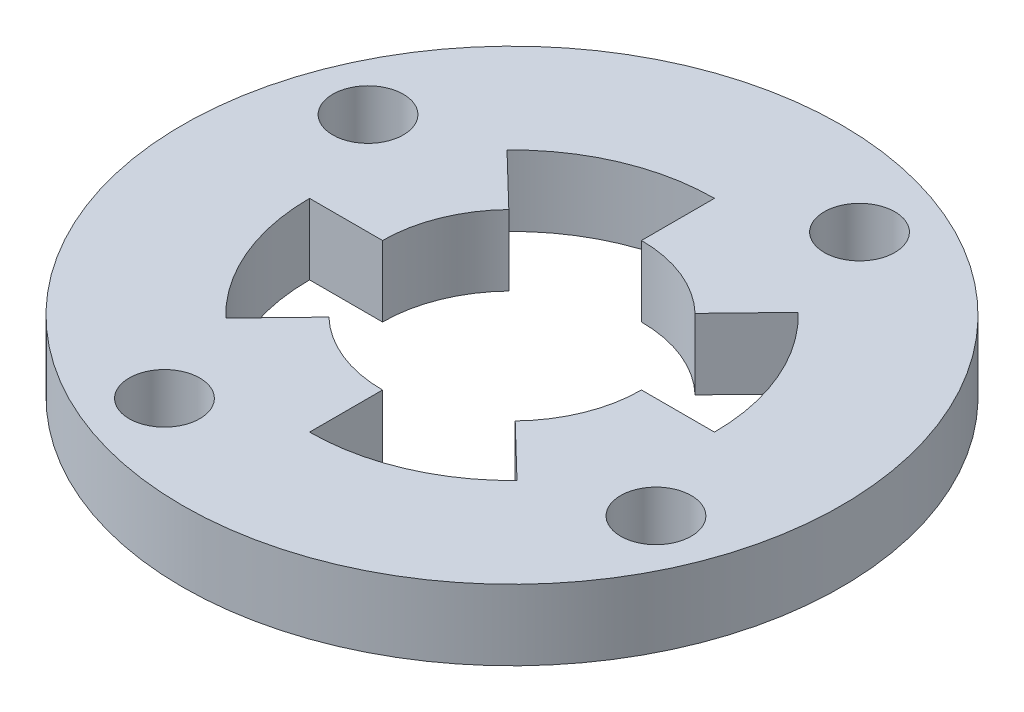
from build123d import *

# Parameters (mm, degrees)
SKETCH1_R           = 14
SKETCH1_R_2         = 1.5
BOSS_EXTRUDE1_DEPTH = 3


with BuildPart() as part:
    # Sketch1 → Boss-Extrude1 (new body)
    with BuildSketch(Plane(origin=(0, 0, 0), x_dir=(1, 0, 0), z_dir=(0, 1, 0))):
        Circle(SKETCH1_R)
        with Locations((-4.324322786, -10.439838717)):
            Circle(SKETCH1_R_2, mode=Mode.SUBTRACT)
        with Locations((10.439838717, -4.324322786)):
            Circle(SKETCH1_R_2, mode=Mode.SUBTRACT)
        with Locations((4.324322786, 10.439838717)):
            Circle(SKETCH1_R_2, mode=Mode.SUBTRACT)
        with Locations((-10.439838717, 4.324322786)):
            Circle(SKETCH1_R_2, mode=Mode.SUBTRACT)
        with BuildLine():
            ThreePointArc((-3.820621038, -3.956368902), (-2.060336264, -5.0995112), (0, -5.5))
            Line((0, -5.5), (0, -8.6))
            ThreePointArc((0, -8.6), (3.360287705, -7.91634174), (6.186322283, -5.974061986))
            Line((6.186322283, -5.974061986), (3.956368902, -3.820621038))
            ThreePointArc((3.956368902, -3.820621038), (5.0995112, -2.060336264), (5.5, 0))
            Line((5.5, 0), (8.6, 0))
            ThreePointArc((8.6, 0), (7.91634174, 3.360287705), (5.974061986, 6.186322283))
            Line((5.974061986, 6.186322283), (3.820621038, 3.956368902))
            ThreePointArc((3.820621038, 3.956368902), (2.060336264, 5.0995112), (0, 5.5))
            Line((0, 5.5), (0, 8.6))
            ThreePointArc((0, 8.6), (-3.360287705, 7.91634174), (-6.186322283, 5.974061986))
            Line((-6.186322283, 5.974061986), (-3.956368902, 3.820621038))
            ThreePointArc((-3.956368902, 3.820621038), (-5.0995112, 2.060336264), (-5.5, 0))
            Line((-5.5, 0), (-8.6, 0))
            ThreePointArc((-8.6, 0), (-7.91634174, -3.360287705), (-5.974061986, -6.186322283))
            Line((-5.974061986, -6.186322283), (-3.820621038, -3.956368902))
        make_face(mode=Mode.SUBTRACT)
    extrude(amount=BOSS_EXTRUDE1_DEPTH)


solid = part.part
